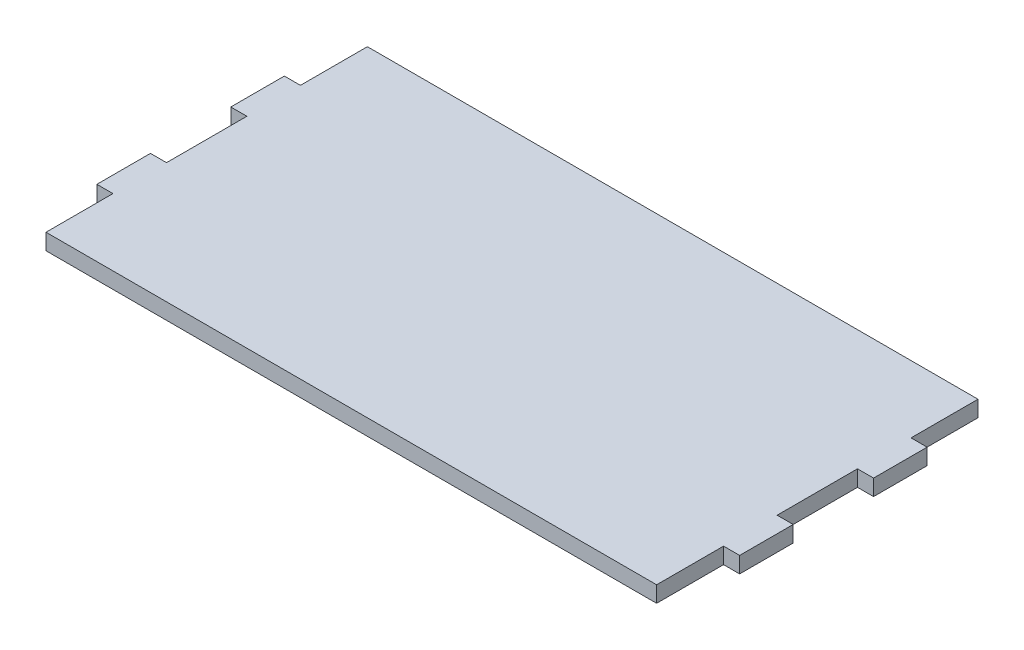
from build123d import *

# Parameters (mm, degrees)
SALIENTE_EXTRUIR1_DEPTH = 3


with BuildPart() as part:
    # Croquis1 → Saliente-Extruir1 (new body)
    with BuildSketch(Plane(origin=(0, 0, 0), x_dir=(1, 0, 0), z_dir=(0, 1, 0))):
        Polygon((-57, 17.5), (-60, 17.5), (-60, 7.5), (-57, 7.5), (-57, -7.5), (-60, -7.5), (-60, -17.5), (-57, -17.5), (-57, -30), (57, -30), (57, -17.5), (60, -17.5), (60, -7.5), (57, -7.5), (57, 7.5), (60, 7.5), (60, 17.5), (57, 17.5), (57, 30), (-57, 30), align=None)
    extrude(amount=SALIENTE_EXTRUIR1_DEPTH)


solid = part.part
